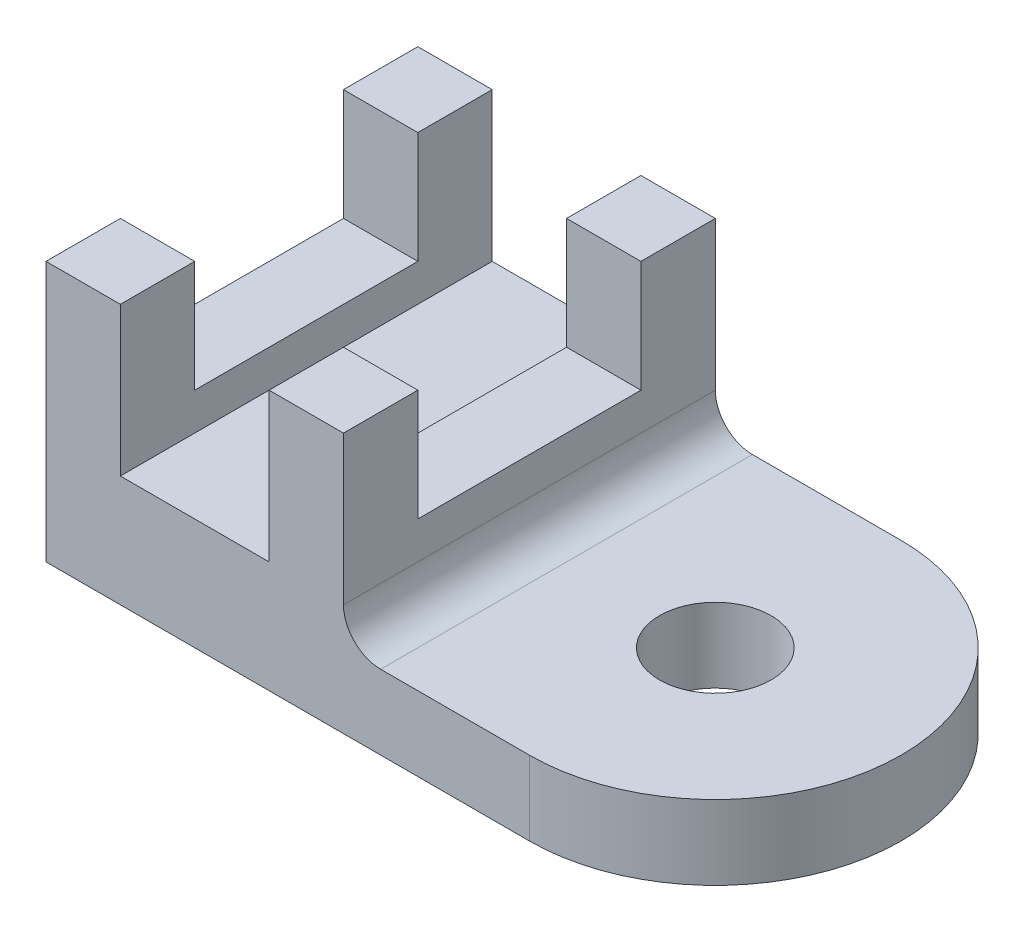
from build123d import *

# Parameters (mm, degrees)
SKETCH1_R           = 9.525
BOSS_EXTRUDE1_DEPTH = 12.7
BOSS_EXTRUDE2_DEPTH = 19.05
SKETCH6_W           = 12.7
SKETCH6_H           = 12.7
BOSS_EXTRUDE3_DEPTH = 25.4
SKETCH6_3_W         = 12.7
SKETCH6_3_H         = 38.1
BOSS_EXTRUDE4_DEPTH = 6.35
FILLET1_R           = 6.35


with BuildPart() as part:
    # Sketch1 → Boss-Extrude1 (new body)
    with BuildSketch(Plane(origin=(0, 0, 0), x_dir=(1, 0, 0), z_dir=(0, 1, 0))):
        with BuildLine():
            Line((82.55, 63.5), (50.8, 63.5))
            Line((50.8, 63.5), (50.8, 0))
            Line((50.8, 0), (82.55, 0))
            ThreePointArc((82.55, 0), (114.3, 31.75), (82.55, 63.5))
        make_face()
        with Locations((82.55, 31.75)):
            Circle(SKETCH1_R, mode=Mode.SUBTRACT)
    extrude(amount=BOSS_EXTRUDE1_DEPTH)

    # Sketch1_4 → Boss-Extrude2 (add)
    with BuildSketch(Plane(origin=(0, 0, 0), x_dir=(1, 0, 0), z_dir=(0, 1, 0))):
        Polygon((50.8, 31.749999876), (50.8, 63.5), (0, 63.5), (0, 0), (50.8, 0), align=None)
    extrude(amount=BOSS_EXTRUDE2_DEPTH)

    # Sketch6 → Boss-Extrude3 (add)
    with BuildSketch(Plane(origin=(0, 19.05, 0), x_dir=(1, 0, 0), z_dir=(0, 1, 0))):
        with Locations((6.35, 57.15)):
            Rectangle(SKETCH6_W, SKETCH6_H)
        with Locations((44.45, 57.15)):
            Rectangle(SKETCH6_W, SKETCH6_H)
        with Locations((6.35, 6.35)):
            Rectangle(SKETCH6_W, SKETCH6_H)
        with Locations((44.45, 6.35)):
            Rectangle(SKETCH6_W, SKETCH6_H)
    extrude(amount=BOSS_EXTRUDE3_DEPTH)

    # Sketch6_3 → Boss-Extrude4 (add)
    with BuildSketch(Plane(origin=(0, 19.05, 0), x_dir=(1, 0, 0), z_dir=(0, 1, 0))):
        with Locations((6.35, 31.75)):
            Rectangle(SKETCH6_3_W, SKETCH6_3_H)
        with Locations((44.45, 31.75)):
            Rectangle(SKETCH6_3_W, SKETCH6_3_H)
    extrude(amount=BOSS_EXTRUDE4_DEPTH)

    # Fillet1
    fillet1_edges = [part.edges().sort_by_distance(p)[0] for p in [
        (50.8, 12.7, -31.75),
    ]]
    fillet(fillet1_edges, radius=FILLET1_R)


solid = part.part
